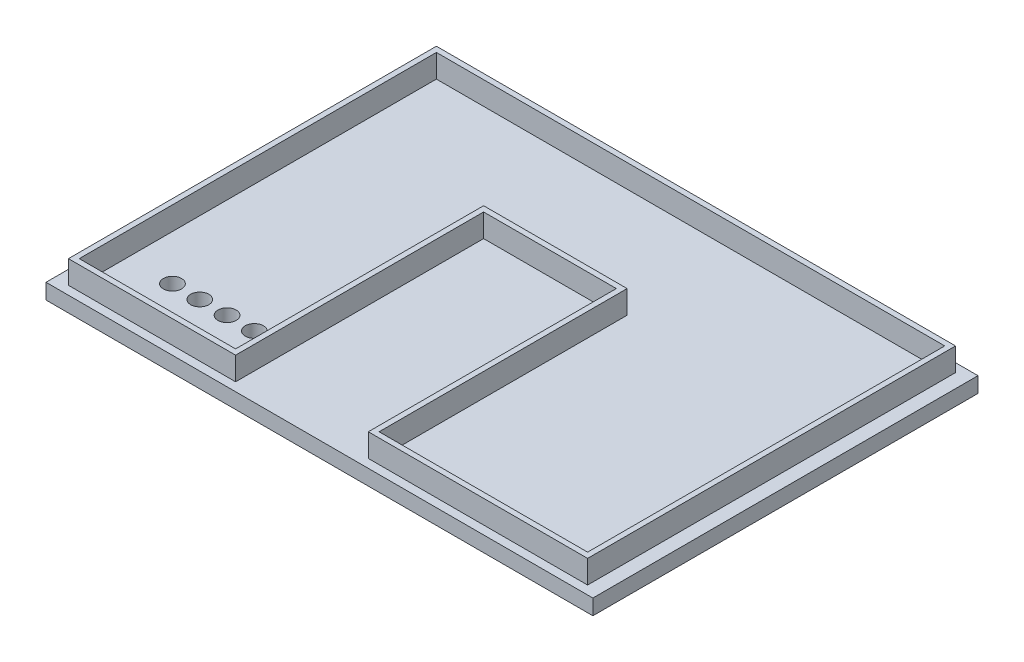
from build123d import *

# Parameters (mm, degrees)
SKETCH1_W           = 180.34
SKETCH1_H           = 127
BOSS_EXTRUDE1_DEPTH = 5.08
BOSS_EXTRUDE2_DEPTH = 7.62
SKETCH3_R           = 3
CUT_EXTRUDE1_DEPTH  = 10.16


with BuildPart() as part:
    # Sketch1 → Boss-Extrude1 (new body)
    with BuildSketch(Plane(origin=(0, 0, 0), x_dir=(1, 0, 0), z_dir=(0, 1, 0))):
        with Locations((90.17, 63.5)):
            Rectangle(SKETCH1_W, SKETCH1_H)
    extrude(amount=BOSS_EXTRUDE1_DEPTH)

    # Sketch2 → Boss-Extrude2 (add)
    with BuildSketch(Plane(origin=(0, 5.08, 0), x_dir=(1, 0, 0), z_dir=(0, 1, 0))):
        Polygon((4.572, 124.1679), (175.768, 124.1679), (175.768, 2.8321), (103.4542, 2.8321), (103.4542, 84.6201), (59.69, 84.6201), (59.69, 2.8321), (4.572, 2.8321), align=None)
        Polygon((6.35, 122.3899), (6.35, 4.6101), (57.912, 4.6101), (57.912, 86.3981), (105.2322, 86.3981), (105.2322, 4.6101), (173.99, 4.6101), (173.99, 122.3899), align=None, mode=Mode.SUBTRACT)
    extrude(amount=BOSS_EXTRUDE2_DEPTH)

    # Sketch3 → Cut-Extrude1 (cut)
    with BuildSketch(Plane.XZ):
        with Locations((21.26, -20.440905976)):
            Circle(SKETCH3_R)
        with Locations((30.26, -20.440905976)):
            Circle(SKETCH3_R)
        with Locations((39.26, -20.440905976)):
            Circle(SKETCH3_R)
        with Locations((48.26, -20.440905976)):
            Circle(SKETCH3_R)
    extrude(amount=-CUT_EXTRUDE1_DEPTH, mode=Mode.SUBTRACT)


solid = part.part
